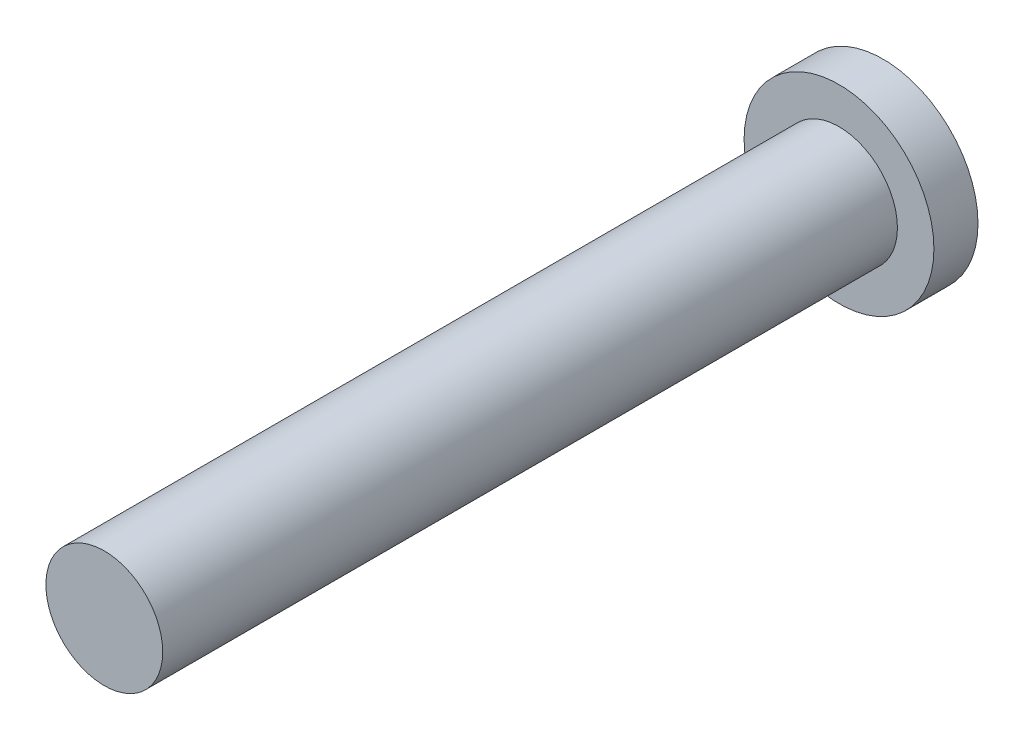
from build123d import *

# Parameters (mm, degrees)
SKETCH1_R           = 2.58375
BOSS_EXTRUDE1_DEPTH = 1.2
SKETCH2_R           = 1.59
BOSS_EXTRUDE2_DEPTH = 20


with BuildPart() as part:
    # Sketch1 → Boss-Extrude1 (new body)
    with BuildSketch(Plane.XY):
        Circle(SKETCH1_R)
    extrude(amount=BOSS_EXTRUDE1_DEPTH)

    # Sketch2 → Boss-Extrude2 (add)
    with BuildSketch(Plane.XY.offset(1.2)):
        Circle(SKETCH2_R)
    extrude(amount=BOSS_EXTRUDE2_DEPTH)


solid = part.part
